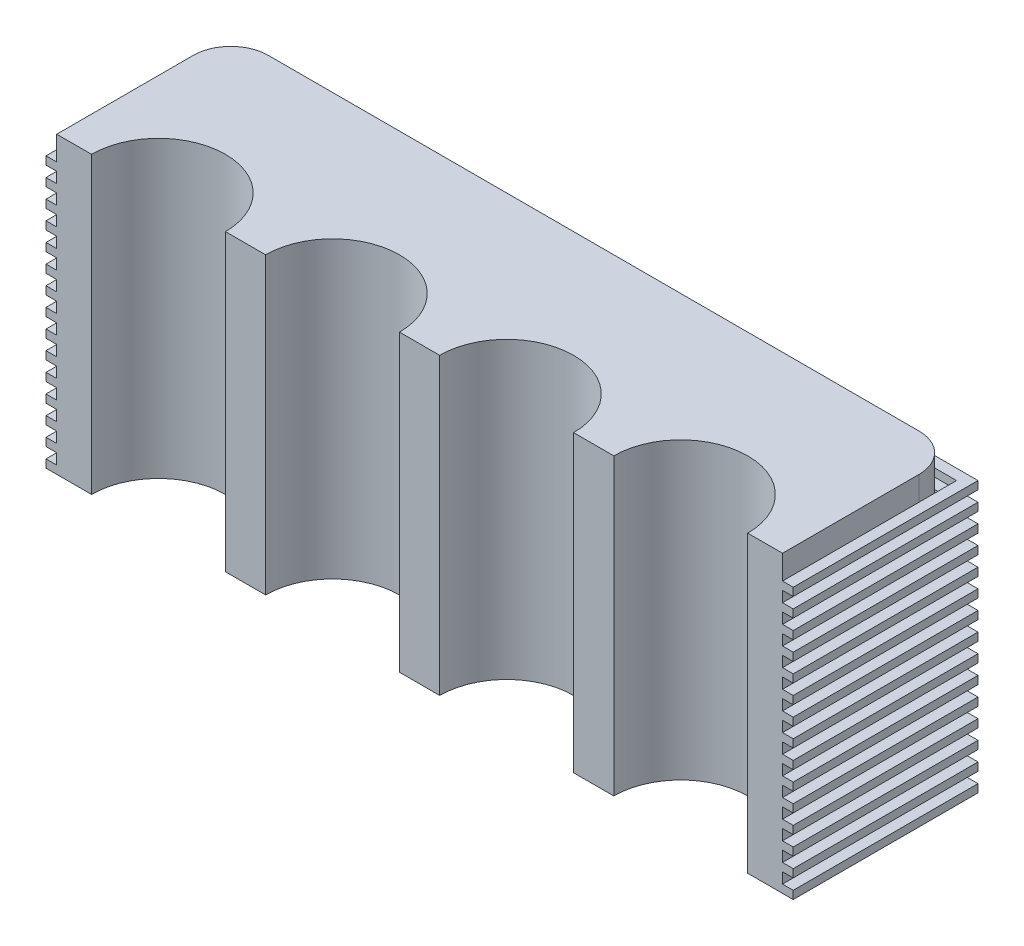
from build123d import *

# Parameters (mm, degrees)
IZIM1_W                     = 279
IZIM1_H                     = 69
Y_KSEKLIK_EKSTR_ZYON2_DEPTH = 110
KES_EKSTR_ZYON1_DEPTH       = 110
IZIM10_W                    = 4
IZIM10_H                    = 9
KES_EKSTR_ZYON5_DEPTH       = 290
IZIM11_W                    = 4
IZIM11_H                    = 9
KES_EKSTR_ZYON6_DEPTH       = 290
IZIM12_W                    = 4
IZIM12_H                    = 9
KES_EKSTR_ZYON7_DEPTH       = 290
IZIM14_W                    = 4
IZIM14_H                    = 3
KES_EKSTR_ZYON8_DEPTH       = 290
IZIM15_W                    = 4
IZIM15_H                    = 3
KES_EKSTR_ZYON9_DEPTH       = 290
IZIM16_W                    = 4
IZIM16_H                    = 3
KES_EKSTR_ZYON12_DEPTH      = 290
IZIM17_W                    = 4
IZIM17_H                    = 95
KES_EKSTR_ZYON13_DEPTH      = 290
IZIM18_W                    = 4
IZIM18_H                    = 95
KES_EKSTR_ZYON14_DEPTH      = 290
IZIM19_W                    = 4
IZIM19_H                    = 95
KES_EKSTR_ZYON15_DEPTH      = 290
KES_EKSTR_ZYON17_DEPTH      = 107
KES_EKSTR_ZYON18_DEPTH      = 107
KES_EKSTR_ZYON19_DEPTH      = 107
Y_KSEKLIK_EKSTR_ZYON3_DEPTH = 3
L_O_ALTMA19_COUNT           = 15
L_O_ALTMA19_PITCH           = 7


with BuildPart() as part:
    # Çizim1 → Yükseklik-Ekstrüzyon2 (new body)
    with BuildSketch(Plane(origin=(0, 0, 0), x_dir=(1, 0, 0), z_dir=(0, 1, 0))):
        with Locations((-15.025887574, 54.923076923)):
            Rectangle(IZIM1_W, IZIM1_H)
    extrude(amount=Y_KSEKLIK_EKSTR_ZYON2_DEPTH)

    # Çizim2 → Kes-Ekstrüzyon1 (cut)
    with BuildSketch(Plane(origin=(0, 110, 0), x_dir=(1, 0, 0), z_dir=(0, 1, 0))):
        with BuildLine():
            Line((-137.525887574, 20.423076923), (-87.525887574, 20.423076923))
            ThreePointArc((-87.525887574, 20.423076923), (-112.525887574, 45.423076923), (-137.525887574, 20.423076923))
        make_face()
        with BuildLine():
            Line((-72.525887574, 20.423076923), (-22.525887574, 20.423076923))
            ThreePointArc((-22.525887574, 20.423076923), (-47.525887574, 45.423076923), (-72.525887574, 20.423076923))
        make_face()
        with BuildLine():
            Line((-7.525887574, 20.423076923), (42.474112426, 20.423076923))
            ThreePointArc((42.474112426, 20.423076923), (17.474112426, 45.423076923), (-7.525887574, 20.423076923))
        make_face()
        with BuildLine():
            Line((57.474112426, 20.423076923), (107.474112426, 20.423076923))
            ThreePointArc((107.474112426, 20.423076923), (82.474112426, 45.423076923), (57.474112426, 20.423076923))
        make_face()
    extrude(amount=-KES_EKSTR_ZYON1_DEPTH, mode=Mode.SUBTRACT)

    # Çizim10 → Kes-Ekstrüzyon5 (cut)
    with BuildSketch(Plane.XY.offset(-20.423076923)):
        with Locations((122.474112426, 105.5)):
            Rectangle(IZIM10_W, IZIM10_H)
    extrude(amount=-KES_EKSTR_ZYON5_DEPTH, mode=Mode.SUBTRACT)

    # Çizim11 → Kes-Ekstrüzyon6 (cut)
    with BuildSketch(Plane(origin=(120.474112426, 0, 0), x_dir=(0, 0, -1), z_dir=(1, 0, 0))):
        with Locations((87.423076923, 105.5)):
            Rectangle(IZIM11_W, IZIM11_H)
    extrude(amount=-KES_EKSTR_ZYON6_DEPTH, mode=Mode.SUBTRACT)

    # Çizim12 → Kes-Ekstrüzyon7 (cut)
    with BuildSketch(Plane(origin=(0, 0, -85.423076923), x_dir=(-1, 0, 0), z_dir=(0, 0, -1))):
        with Locations((152.525887574, 105.5)):
            Rectangle(IZIM12_W, IZIM12_H)
    extrude(amount=-KES_EKSTR_ZYON7_DEPTH, mode=Mode.SUBTRACT)

    # Çizim14 → Kes-Ekstrüzyon8 (cut)
    with BuildSketch(Plane(origin=(0, 0, -89.423076923), x_dir=(-1, 0, 0), z_dir=(0, 0, -1))):
        with Locations((-122.474112426, 4.5)):
            Rectangle(IZIM14_W, IZIM14_H)
    extrude(amount=-KES_EKSTR_ZYON8_DEPTH, mode=Mode.SUBTRACT)

    # Çizim15 → Kes-Ekstrüzyon9 (cut)
    with BuildSketch(Plane(origin=(120.474112426, 0, 0), x_dir=(0, 0, -1), z_dir=(1, 0, 0))):
        with Locations((87.423076923, 4.5)):
            Rectangle(IZIM15_W, IZIM15_H)
    extrude(amount=-KES_EKSTR_ZYON9_DEPTH, mode=Mode.SUBTRACT)

    # Çizim16 → Kes-Ekstrüzyon12 (cut)
    with BuildSketch(Plane(origin=(0, 0, -85.423076923), x_dir=(-1, 0, 0), z_dir=(0, 0, -1))):
        with Locations((152.525887574, 4.5)):
            Rectangle(IZIM16_W, IZIM16_H)
    extrude(amount=-KES_EKSTR_ZYON12_DEPTH, mode=Mode.SUBTRACT)

    # Çizim17 → Kes-Ekstrüzyon13 (cut)
    with BuildSketch(Plane.ZY.offset(154.525887574)):
        with Locations((-87.423076923, 53.5)):
            Rectangle(IZIM17_W, IZIM17_H)
    extrude(amount=-KES_EKSTR_ZYON13_DEPTH, mode=Mode.SUBTRACT)

    # Çizim18 → Kes-Ekstrüzyon14 (cut)
    with BuildSketch(Plane.XY.offset(-20.423076923)):
        with Locations((-152.525887574, 53.5)):
            Rectangle(IZIM18_W, IZIM18_H)
    extrude(amount=-KES_EKSTR_ZYON14_DEPTH, mode=Mode.SUBTRACT)

    # Çizim19 → Kes-Ekstrüzyon15 (cut)
    with BuildSketch(Plane.XY.offset(-20.423076923)):
        with Locations((122.474112426, 53.5)):
            Rectangle(IZIM19_W, IZIM19_H)
    extrude(amount=-KES_EKSTR_ZYON15_DEPTH, mode=Mode.SUBTRACT)

    # Çizim22 → Kes-Ekstrüzyon17 (cut)
    with BuildSketch(Plane(origin=(0, 110, 0), x_dir=(1, 0, 0), z_dir=(0, 1, 0))):
        with BuildLine():
            Line((-136.525887574, 85.423076923), (-150.525887574, 85.423076923))
            Line((-150.525887574, 85.423076923), (-150.525887574, 71.423076923))
            ThreePointArc((-150.525887574, 71.423076923), (-146.425382511, 81.32257186), (-136.525887574, 85.423076923))
        make_face()
        with BuildLine():
            Line((120.474112426, 71.423076923), (120.474112426, 85.423076923))
            Line((120.474112426, 85.423076923), (106.474112426, 85.423076923))
            ThreePointArc((106.474112426, 85.423076923), (116.373607363, 81.32257186), (120.474112426, 71.423076923))
        make_face()
    extrude(amount=-KES_EKSTR_ZYON17_DEPTH, mode=Mode.SUBTRACT)

    # Çizim23 → Kes-Ekstrüzyon18 (cut)
    with BuildSketch(Plane(origin=(0, 3, 0), x_dir=(1, 0, 0), z_dir=(0, 1, 0))):
        Polygon((-150.525887574, 20.423076923), (-154.525887574, 20.423076923), (-154.525887574, 89.423076923), (124.474112426, 89.423076923), (124.474112426, 20.423076923), (120.474112426, 20.423076923), (120.474112426, 85.423076923), (-150.525887574, 85.423076923), align=None)
    extrude(amount=-KES_EKSTR_ZYON18_DEPTH, mode=Mode.SUBTRACT)

    # Çizim25 → Kes-Ekstrüzyon19 (cut)
    with BuildSketch(Plane.XZ):
        with BuildLine():
            Line((120.474112426, -71.423076923), (120.474112426, -85.423076923))
            Line((120.474112426, -85.423076923), (106.474112426, -85.423076923))
            ThreePointArc((106.474112426, -85.423076923), (116.373607363, -81.32257186), (120.474112426, -71.423076923))
        make_face()
        with BuildLine():
            Line((-150.525887574, -85.423076923), (-136.525887574, -85.423076923))
            ThreePointArc((-136.525887574, -85.423076923), (-146.425382511, -81.32257186), (-150.525887574, -71.423076923))
            Line((-150.525887574, -71.423076923), (-150.525887574, -85.423076923))
        make_face()
    extrude(amount=-KES_EKSTR_ZYON19_DEPTH, mode=Mode.SUBTRACT)

    # Çizim27 → Yükseklik-Ekstrüzyon3 (add)
    with BuildSketch(Plane.XZ):
        Polygon((120.474112426, -20.423076923), (124.474112426, -20.423076923), (124.474112426, -89.423076923), (-154.525887574, -89.423076923), (-154.525887574, -20.423076923), (-150.525887574, -20.423076923), (-150.525887574, -85.423076923), (120.474112426, -85.423076923), align=None)
    y_kseklik_ekstr_zyon3 = extrude(amount=-Y_KSEKLIK_EKSTR_ZYON3_DEPTH)

    # LÇoğaltma19: Yükseklik-Ekstrüzyon3 ×15
    with Locations(*[(0, i * L_O_ALTMA19_PITCH, 0) for i in range(1, L_O_ALTMA19_COUNT)]):
        add(y_kseklik_ekstr_zyon3)


solid = part.part
